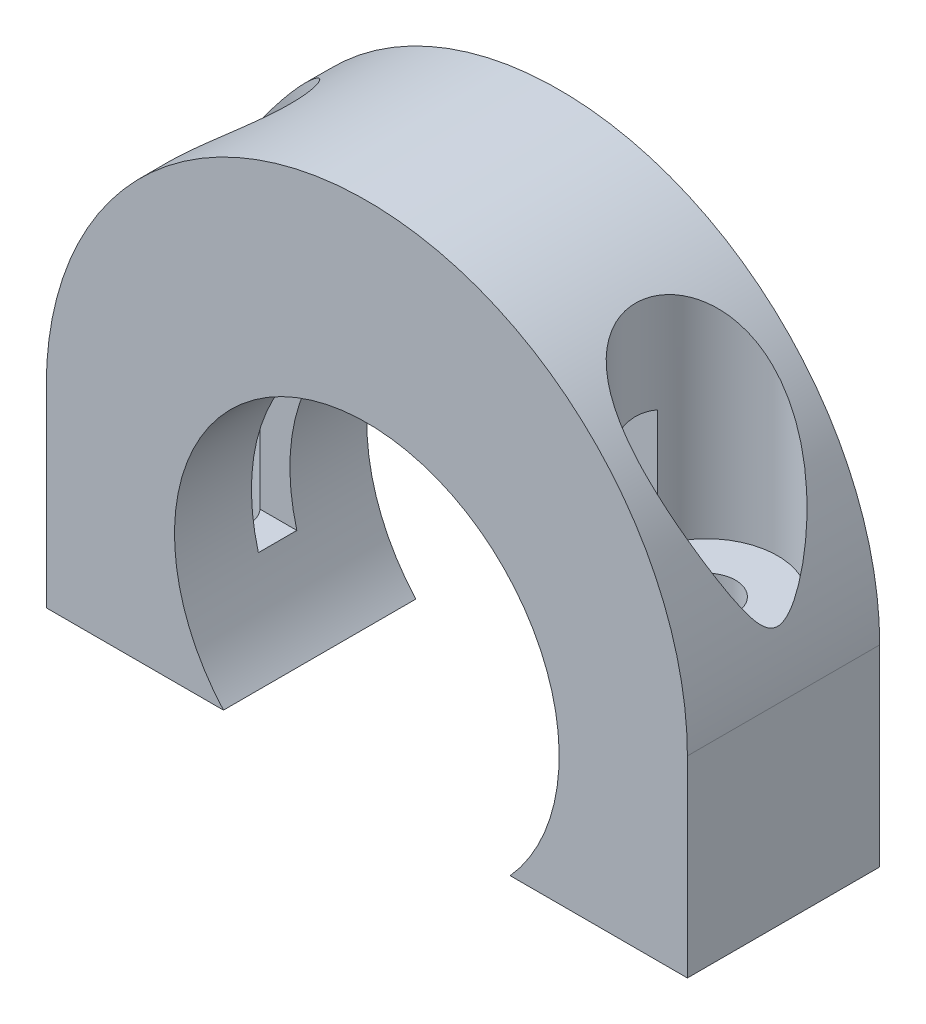
from build123d import *

# Parameters (mm, degrees)
BOSS_EXTRUDE1_DEPTH = 15
SHELL2_T            = 6
CUT_EXTRUDE1_REACH  = 17
SKETCH2_R           = 15
CUT_EXTRUDE2_REACH  = 42
SKETCH3_R           = 2.25
SKETCH5_R           = 5.54
CUT_EXTRUDE3_DEPTH  = 21


with BuildPart() as part:
    # Sketch1 → Boss-Extrude1 (new body)
    with BuildSketch(Plane.XY):
        with BuildLine():
            Line((-25, 0), (-25, -15))
            Line((-25, -15), (25, -15))
            Line((25, -15), (25, 0))
            ThreePointArc((25, 0), (0, 25), (-25, 0))
        make_face()
    extrude(amount=BOSS_EXTRUDE1_DEPTH)

    # Shell2 (no face opened: a closed hollow body)
    add(offset(amount=-SHELL2_T, mode=Mode.PRIVATE), mode=Mode.SUBTRACT)

    # Sketch2 → Cut-Extrude1 (cut, up to next)
    with BuildSketch(Plane.XY.offset(15), mode=Mode.PRIVATE) as cut_extrude1_sk1:
        with Locations((0, -5)):
            Circle(SKETCH2_R)
    cut_extrude1_tool1 = extrude(cut_extrude1_sk1.sketch, amount=-CUT_EXTRUDE1_REACH, mode=Mode.PRIVATE) & part.part
    add(cut_extrude1_tool1.solids().sort_by_distance((0, -5, 15))[0], mode=Mode.SUBTRACT)

    # Sketch3 → Cut-Extrude2 (cut, up to next)
    with BuildSketch(Plane(origin=(0, 25, 0), x_dir=(1, 0, 0), z_dir=(0, 1, 0)), mode=Mode.PRIVATE) as cut_extrude2_sk1:
        with Locations((-19, -7.5)):
            Circle(SKETCH3_R)
    cut_extrude2_tool1 = extrude(cut_extrude2_sk1.sketch, amount=-CUT_EXTRUDE2_REACH, mode=Mode.PRIVATE) & part.part
    add(cut_extrude2_tool1.solids().sort_by_distance((-19, 25, 7.5))[0], mode=Mode.SUBTRACT)
    # Sketch3 → Cut-Extrude2 (cut, up to next)
    with BuildSketch(Plane(origin=(0, 25, 0), x_dir=(1, 0, 0), z_dir=(0, 1, 0)), mode=Mode.PRIVATE) as cut_extrude2_sk2:
        with Locations((19, -7.5)):
            Circle(SKETCH3_R)
    cut_extrude2_tool2 = extrude(cut_extrude2_sk2.sketch, amount=-CUT_EXTRUDE2_REACH, mode=Mode.PRIVATE) & part.part
    add(cut_extrude2_tool2.solids().sort_by_distance((19, 25, 7.5))[0], mode=Mode.SUBTRACT)

    # Sketch5 → Cut-Extrude3 (cut)
    with BuildSketch(Plane(origin=(0, 25, 0), x_dir=(1, 0, 0), z_dir=(0, 1, 0))):
        with Locations((19, -7.5)):
            Circle(SKETCH5_R)
        with Locations((-19, -7.5)):
            Circle(SKETCH5_R)
    extrude(amount=-CUT_EXTRUDE3_DEPTH, mode=Mode.SUBTRACT)


solid = part.part
